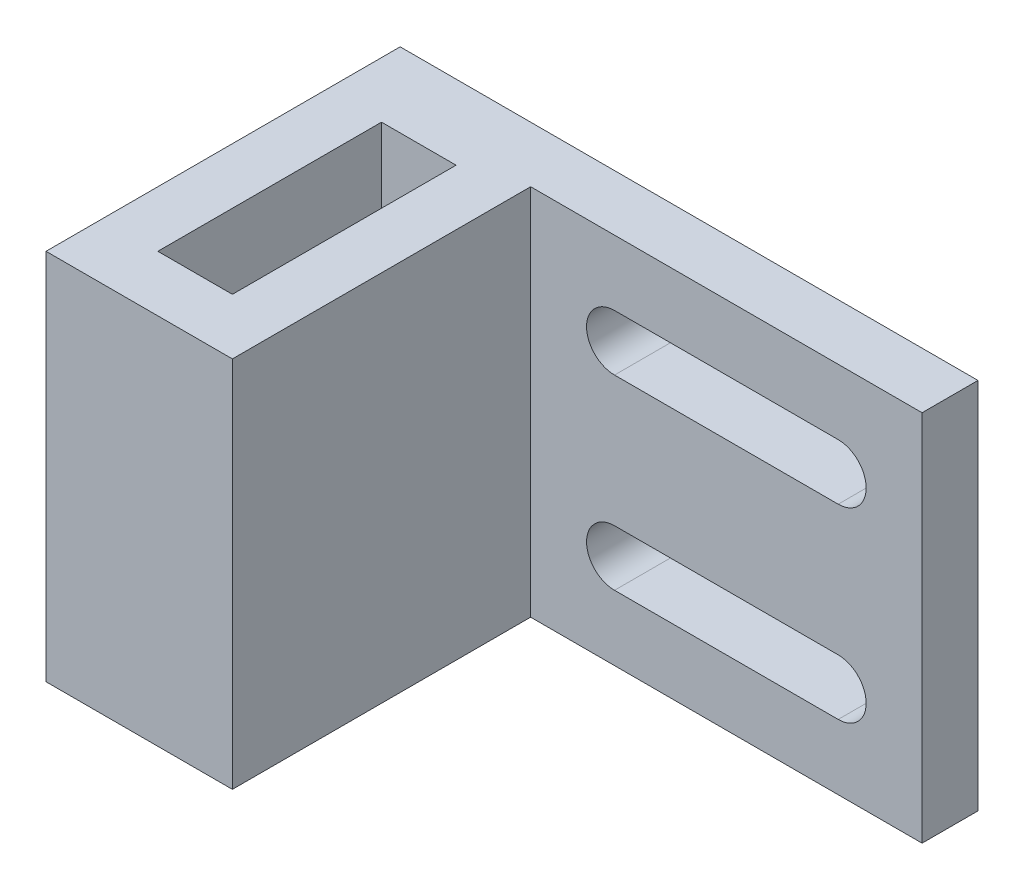
from build123d import *

# Parameters (mm, degrees)
SALIENTE_EXTRUIR1_DEPTH = 20
CORTAR_EXTRUIR1_DEPTH   = 20
CROQUIS3_W              = 4
CROQUIS3_H              = 20
SALIENTE_EXTRUIR2_DEPTH = 5


with BuildPart() as part:
    # Croquis1 → Saliente-Extruir1 (new body)
    with BuildSketch(Plane(origin=(0, 0, 0), x_dir=(1, 0, 0), z_dir=(0, 1, 0))):
        Polygon((-5, 19), (-2, 19), (-2, 3), (2, 3), (2, 19), (26, 19), (26, 16), (5, 16), (5, 0), (-5, 0), align=None)
    extrude(amount=SALIENTE_EXTRUIR1_DEPTH)

    # Croquis2 → Cortar-Extruir1 (cut)
    with BuildSketch(Plane.XY.offset(-16)):
        with BuildLine():
            Line((21.5, 16.5), (9.5, 16.5))
            ThreePointArc((9.5, 16.5), (8, 15), (9.5, 13.5))
            Line((9.5, 13.5), (21.5, 13.5))
            ThreePointArc((21.5, 13.5), (23, 15), (21.5, 16.5))
        make_face()
        with BuildLine():
            Line((21.5, 3.5), (9.5, 3.5))
            ThreePointArc((9.5, 3.5), (8, 5), (9.5, 6.5))
            Line((9.5, 6.5), (21.5, 6.5))
            ThreePointArc((21.5, 6.5), (23, 5), (21.5, 3.5))
        make_face()
    extrude(amount=-CORTAR_EXTRUIR1_DEPTH, mode=Mode.SUBTRACT)

    # Croquis3 → Saliente-Extruir2 (add)
    with BuildSketch(Plane(origin=(-2, 0, 0), x_dir=(0, 0, -1), z_dir=(1, 0, 0))):
        with Locations((17, 10)):
            Rectangle(CROQUIS3_W, CROQUIS3_H)
    extrude(amount=SALIENTE_EXTRUIR2_DEPTH)


solid = part.part
